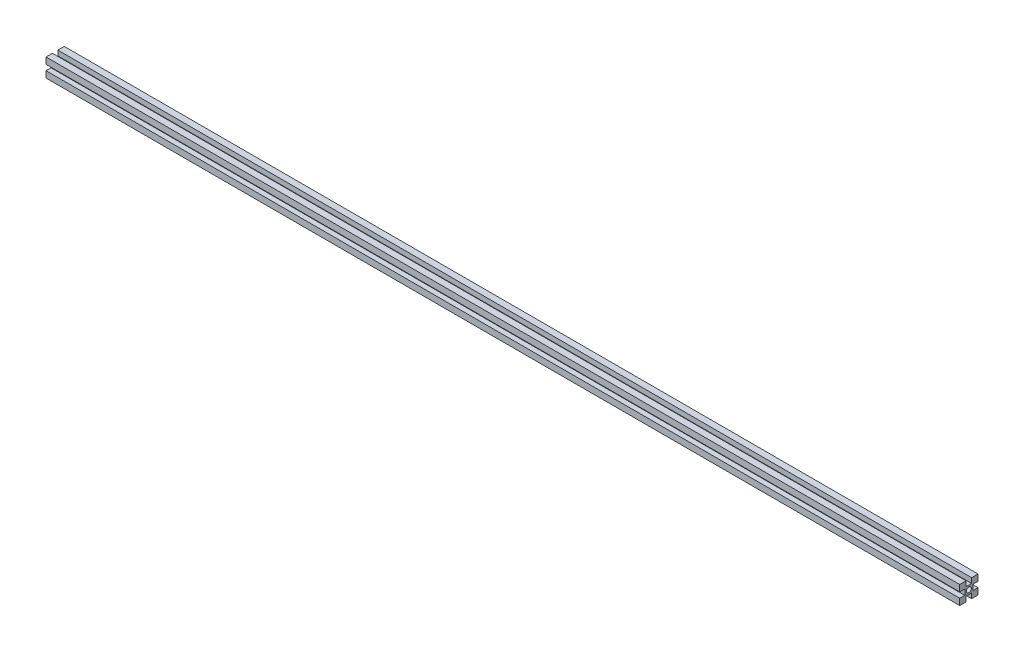
from build123d import *

# Parameters (mm, degrees)
ESQUISSE1_R        = 2.75
BOSS_EXTRU_1_DEPTH = 1000


with BuildPart() as part:
    # Esquisse1 → Boss.-Extru.1 (new body)
    with BuildSketch(Plane(origin=(0, 0, 0), x_dir=(0, -1, 0), z_dir=(-1, 0, 0))):
        Polygon((-3, -10), (-3, -4.5), (3, -4.5), (3, -10), (10, -10), (10, -3), (4.5, -3), (4.5, 3), (10, 3), (10, 10), (3, 10), (3, 4.5), (-3, 4.5), (-3, 10), (-10, 10), (-10, 3), (-4.5, 3), (-4.5, -3), (-10, -3), (-10, -10), align=None)
        Circle(ESQUISSE1_R, mode=Mode.SUBTRACT)
    extrude(amount=-BOSS_EXTRU_1_DEPTH)


solid = part.part
